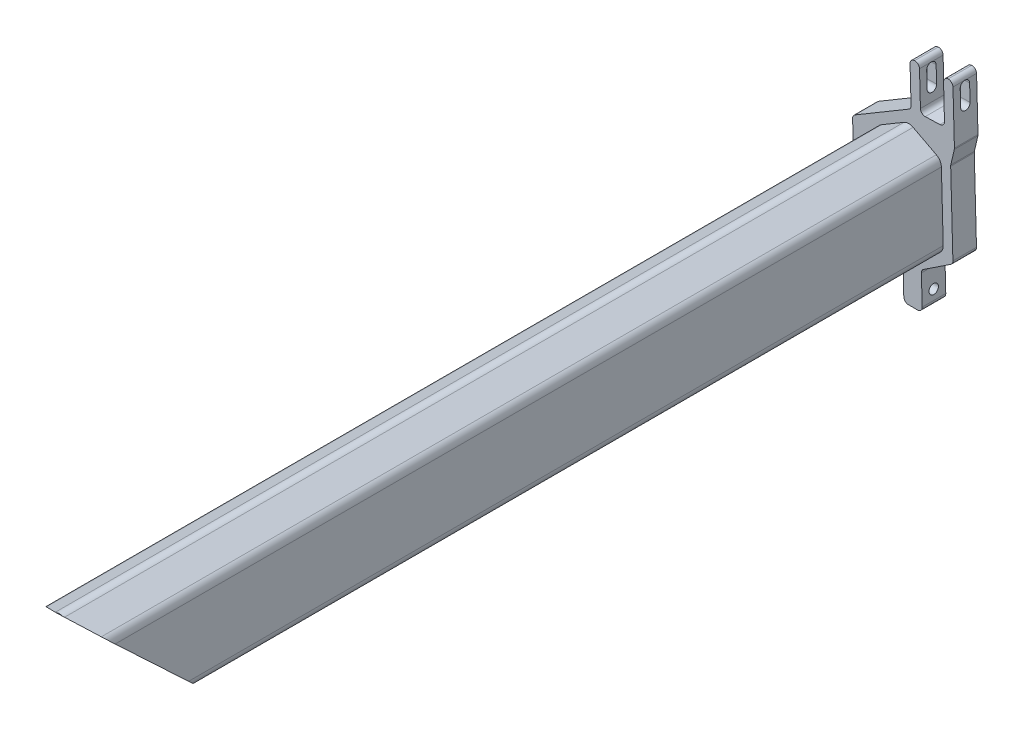
from build123d import *

# Parameters (mm, degrees)
BOSS_EXTRUDE1_DEPTH = 5
BOSS_EXTRUDE2_DEPTH = 180
SKETCH3_R           = 1
CUT_EXTRUDE1_DEPTH  = 180


with BuildPart() as part:
    # Sketch1 → Boss-Extrude1 (new body)
    with BuildSketch(Plane.XY):
        with BuildLine():
            Line((217.13080024, 186.236980413), (217.522895205, 171.902828405))
            ThreePointArc((217.522895205, 171.902828405), (217.676624689, 171.396825166), (218.066927795, 171.039984141))
            Line((218.066927795, 171.039984141), (227.253610039, 166.338288505))
            ThreePointArc((227.253610039, 166.338288505), (227.643913146, 165.981447481), (227.79764263, 165.475444242))
            Line((227.79764263, 165.475444242), (227.976831168, 158.924695096))
            ThreePointArc((227.976831168, 158.924695096), (228.279084932, 158.235329737), (228.97645726, 157.952038769))
            Line((228.97645726, 157.952038769), (230.8781853, 157.952038769))
            ThreePointArc((230.8781853, 157.952038769), (231.594894332, 158.254666441), (231.877811392, 158.979382441))
            Line((231.877811392, 158.979382441), (231.708538067, 165.167652598))
            ThreePointArc((231.708538067, 165.167652598), (231.820970232, 165.656392994), (232.156538916, 166.029088346))
            Line((232.156538916, 166.029088346), (237.939045309, 169.853338197))
            ThreePointArc((237.939045309, 169.853338197), (238.274613993, 170.226033549), (238.387046158, 170.714773945))
            Line((238.387046158, 170.714773945), (237.918224361, 187.853894574))
            ThreePointArc((237.918224361, 187.853894574), (237.922769134, 187.980299684), (237.94323412, 188.105119919))
            Line((237.94323412, 188.105119919), (238.683490474, 191.327652279))
            ThreePointArc((238.683490474, 191.327652279), (238.70395546, 191.452472514), (238.708500233, 191.578877624))
            Line((238.708500233, 191.578877624), (238.40594927, 202.639492732))
            ThreePointArc((238.40594927, 202.639492732), (238.093830671, 203.338326344), (237.37823169, 203.611754696))
            ThreePointArc((237.37823169, 203.611754696), (236.679398078, 203.299636096), (236.40594927, 202.584784932))
            Line((236.40594927, 202.584784932), (236.602823712, 195.38747707))
            ThreePointArc((236.602823712, 195.38747707), (236.329374904, 194.672625906), (235.630541293, 194.360507306))
            Line((235.630541293, 194.360507306), (232.531700408, 194.275741921))
            ThreePointArc((232.531700408, 194.275741921), (231.816849243, 194.549190729), (231.504730643, 195.248024341))
            Line((231.504730643, 195.248024341), (231.307856202, 202.445332202))
            ThreePointArc((231.307856202, 202.445332202), (230.995737602, 203.144165814), (230.280138621, 203.417594166))
            ThreePointArc((230.280138621, 203.417594166), (229.581305009, 203.105475566), (229.307856202, 202.390624402))
            Line((229.307856202, 202.390624402), (229.516006509, 194.781095054))
            ThreePointArc((229.516006509, 194.781095054), (229.392075465, 194.270886823), (229.026740392, 193.893790513))
            Line((229.026740392, 193.893790513), (217.620066357, 187.124284954))
            ThreePointArc((217.620066357, 187.124284954), (217.254731284, 186.747188644), (217.13080024, 186.236980413))
        make_face()
        with BuildLine():
            Line((228.516569513, 190.102489168), (223.742260028, 187.269085277))
            ThreePointArc((223.742260028, 187.269085277), (223.376924955, 186.891988967), (223.252993911, 186.381780736))
            Line((223.252993911, 186.381780736), (223.642537472, 172.14090257))
            ThreePointArc((223.642537472, 172.14090257), (223.796266956, 171.634899331), (224.186570063, 171.278058307))
            Line((224.186570063, 171.278058307), (229.107271966, 168.759668963))
            ThreePointArc((229.107271966, 168.759668963), (229.59020914, 168.650230807), (230.066441509, 168.785905991))
            Line((230.066441509, 168.785905991), (234.842112696, 171.569528957))
            ThreePointArc((234.842112696, 171.569528957), (235.212324771, 171.947173038), (235.338162748, 172.460823537))
            Line((235.338162748, 172.460823537), (234.948619186, 186.701701703))
            ThreePointArc((234.948619186, 186.701701703), (234.796981963, 187.204372068), (234.41157851, 187.560932751))
            Line((234.41157851, 187.560932751), (229.489514903, 190.12910302))
            ThreePointArc((229.489514903, 190.12910302), (228.999585816, 190.242154392), (228.516569513, 190.102489168))
        make_face(mode=Mode.SUBTRACT)
    extrude(amount=BOSS_EXTRUDE1_DEPTH)

    # Sketch2 → Boss-Extrude2 (add)
    with BuildSketch(Plane.XY.offset(5)):
        with BuildLine():
            Line((228.006209537, 190.962450037), (223.231900052, 188.129046145))
            ThreePointArc((223.231900052, 188.129046145), (222.501229906, 187.374853526), (222.253367819, 186.354437063))
            Line((222.253367819, 186.354437063), (222.642911381, 172.113558898))
            ThreePointArc((222.642911381, 172.113558898), (222.950370347, 171.10155242), (223.730976561, 170.387870371))
            Line((223.730976561, 170.387870371), (228.651678464, 167.869481027))
            ThreePointArc((228.651678464, 167.869481027), (229.617552813, 167.650604715), (230.57001755, 167.921955083))
            Line((230.57001755, 167.921955083), (235.345688737, 170.705578049))
            ThreePointArc((235.345688737, 170.705578049), (236.086112886, 171.460866211), (236.337788839, 172.48816721))
            Line((236.337788839, 172.48816721), (235.948245278, 186.729045376))
            ThreePointArc((235.948245278, 186.729045376), (235.644970831, 187.734386104), (234.874163925, 188.44750747))
            Line((234.874163925, 188.44750747), (229.952100319, 191.015677739))
            ThreePointArc((229.952100319, 191.015677739), (228.972242143, 191.241780484), (228.006209537, 190.962450037))
        make_face()
        with BuildLine():
            Line((223.252993911, 186.381780736), (223.642537472, 172.14090257))
            ThreePointArc((223.642537472, 172.14090257), (223.796266956, 171.634899331), (224.186570063, 171.278058307))
            Line((224.186570063, 171.278058307), (229.107271966, 168.759668963))
            ThreePointArc((229.107271966, 168.759668963), (229.59020914, 168.650230807), (230.066441509, 168.785905991))
            Line((230.066441509, 168.785905991), (234.842112696, 171.569528957))
            ThreePointArc((234.842112696, 171.569528957), (235.212324771, 171.947173038), (235.338162748, 172.460823537))
            Line((235.338162748, 172.460823537), (234.948619186, 186.701701703))
            ThreePointArc((234.948619186, 186.701701703), (234.796981963, 187.204372068), (234.41157851, 187.560932751))
            Line((234.41157851, 187.560932751), (229.489514903, 190.12910302))
            ThreePointArc((229.489514903, 190.12910302), (228.999585816, 190.242154392), (228.516569513, 190.102489168))
            Line((228.516569513, 190.102489168), (223.742260028, 187.269085277))
            ThreePointArc((223.742260028, 187.269085277), (223.376924955, 186.891988967), (223.252993911, 186.381780736))
        make_face(mode=Mode.SUBTRACT)
    extrude(amount=BOSS_EXTRUDE2_DEPTH)

    # Sketch3 → Cut-Extrude1 (cut)
    with BuildSketch(Plane(origin=(227.180903608, 6.214283783, 0), x_dir=(0, 0, 1), z_dir=(-0.999626092, -0.027343672, 0))):
        with Locations((2.5, 154.631921977)):
            Circle(SKETCH3_R)
        Polygon((185, 184.782926083), (185, 161.309331644), (160, 161.309331644), align=None)
        with BuildLine():
            Line((3.5, 195.044829999), (3.5, 191.544829999))
            ThreePointArc((3.5, 191.544829999), (2.5, 190.544829999), (1.5, 191.544829999))
            Line((1.5, 191.544829999), (1.5, 195.044829999))
            ThreePointArc((1.5, 195.044829999), (2.5, 196.044829999), (3.5, 195.044829999))
        make_face()
    extrude(amount=-CUT_EXTRUDE1_DEPTH, mode=Mode.SUBTRACT)


solid = part.part
